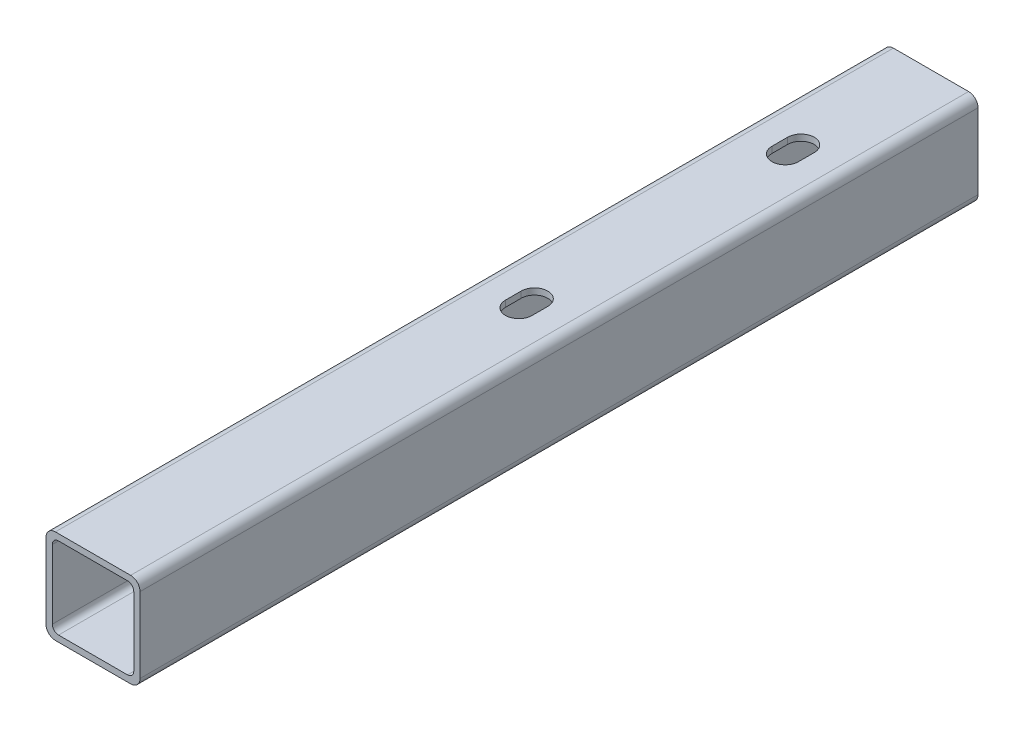
from build123d import *

# Parameters (mm, degrees)
EXTRUDE_1_DEPTH     = 267.336309
CUT_EXTRUDE_1_DEPTH = 31
CUT_EXTRUDE_2_DEPTH = 10


with BuildPart() as part:
    # Эскиз1 → Бобышка-Вытянуть1 (new body)
    with BuildSketch(Plane.XY):
        with BuildLine():
            Line((3, 0), (27, 0))
            ThreePointArc((27, 0), (29.121320344, -0.878679656), (30, -3))
            Line((30, -3), (30, -27))
            ThreePointArc((30, -27), (29.121320344, -29.121320344), (27, -30))
            Line((27, -30), (3, -30))
            ThreePointArc((3, -30), (0.878679656, -29.121320344), (0, -27))
            Line((0, -27), (0, -3))
            ThreePointArc((0, -3), (0.878679656, -0.878679656), (3, 0))
        make_face()
        with BuildLine():
            Line((4, -2), (26, -2))
            ThreePointArc((26, -2), (27.414213562, -2.585786438), (28, -4))
            Line((28, -4), (28, -26))
            ThreePointArc((28, -26), (27.414213562, -27.414213562), (26, -28))
            Line((26, -28), (4, -28))
            ThreePointArc((4, -28), (2.585786438, -27.414213562), (2, -26))
            Line((2, -26), (2, -4))
            ThreePointArc((2, -4), (2.585786438, -2.585786438), (4, -2))
        make_face(mode=Mode.SUBTRACT)
    extrude(amount=-EXTRUDE_1_DEPTH)

    # Эскиз2 → Вырез-Вытянуть1 (cut, through all)
    with BuildSketch(Plane.XZ.offset(30)):
        with BuildLine():
            Line((19.25, -135.836309448), (19.25, -140.836309448))
            ThreePointArc((19.25, -140.836309448), (15, -145.086309448), (10.75, -140.836309448))
            Line((10.75, -140.836309448), (10.75, -135.836309448))
            ThreePointArc((10.75, -135.836309448), (15, -131.586309448), (19.25, -135.836309448))
        make_face()
        with BuildLine():
            Line((10.75, -225.836309448), (10.75, -220.836309448))
            ThreePointArc((10.75, -220.836309448), (15, -216.586309448), (19.25, -220.836309448))
            Line((19.25, -220.836309448), (19.25, -225.836309448))
            ThreePointArc((19.25, -225.836309448), (15, -230.086309448), (10.75, -225.836309448))
        make_face()
    extrude(amount=-CUT_EXTRUDE_1_DEPTH, mode=Mode.SUBTRACT)

    # Эскиз3 → Вырез-Вытянуть2 (cut)
    with BuildSketch(Plane.XZ.offset(30)):
        with BuildLine():
            Line((5, -140.836309448), (5, -135.836309448))
            ThreePointArc((5, -135.836309448), (15, -125.836309448), (25, -135.836309448))
            Line((25, -135.836309448), (25, -140.836309448))
            ThreePointArc((25, -140.836309448), (15, -150.836309448), (5, -140.836309448))
        make_face()
        with BuildLine():
            Line((5, -225.836309448), (5, -220.836309448))
            ThreePointArc((5, -220.836309448), (15, -210.836309448), (25, -220.836309448))
            Line((25, -220.836309448), (25, -225.836309448))
            ThreePointArc((25, -225.836309448), (15, -235.836309448), (5, -225.836309448))
        make_face()
    extrude(amount=-CUT_EXTRUDE_2_DEPTH, mode=Mode.SUBTRACT)


solid = part.part
